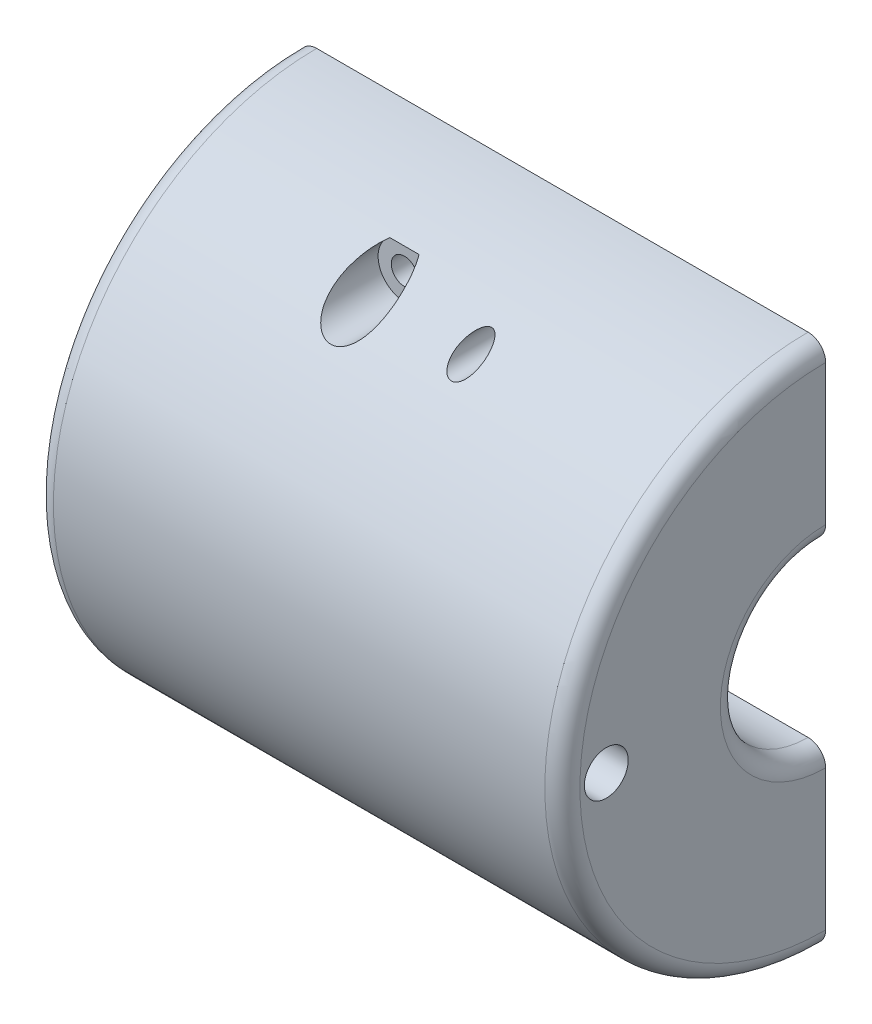
from build123d import *

# Parameters (mm, degrees)
SKETCH1_R               = 38.1
BOSS_EXTRUDE1_DEPTH     = 25.4
SKETCH2_R               = 38.1
SKETCH2_R_2             = 25.4
BOSS_EXTRUDE2_DEPTH     = 25.4
SKETCH3_R               = 38.1
BOSS_EXTRUDE3_DEPTH     = 25.4
SKETCH4_R               = 12.7
CUT_EXTRUDE1_DEPTH      = 77.2
FILLET1_R               = 2.54
SKETCH6_R               = 1.905
CUT_EXTRUDE2_DEPTH      = 39.1000001
CUT_EXTRUDE2_DEPTH_BACK = 39.1000001
SKETCH7_R               = 3.81
CUT_EXTRUDE3_DEPTH      = 25.4
SKETCH8_R               = 3.81
CUT_EXTRUDE4_DEPTH      = 25.4
CUT_EXTRUDE5_REACH      = 78.2
SKETCH9_W               = 50.8
SKETCH9_H               = 76.2
FILLET2_R               = 2.54
SKETCH10_R              = 3.175
CUT_EXTRUDE6_DEPTH      = 77.2
FILLET3_R               = 2.54


with BuildPart() as part:
    # Sketch1 → Boss-Extrude1 (new body)
    with BuildSketch(Plane(origin=(0, 0, 0), x_dir=(0, 0, -1), z_dir=(1, 0, 0))):
        Circle(SKETCH1_R)
    extrude(amount=BOSS_EXTRUDE1_DEPTH)

    # Sketch2 → Boss-Extrude2 (add)
    with BuildSketch(Plane(origin=(25.4, 0, 0), x_dir=(0, 0, -1), z_dir=(1, 0, 0))):
        Circle(SKETCH2_R)
        Circle(SKETCH2_R_2, mode=Mode.SUBTRACT)
    extrude(amount=BOSS_EXTRUDE2_DEPTH)

    # Sketch3 → Boss-Extrude3 (add)
    with BuildSketch(Plane(origin=(50.8, 0, 0), x_dir=(0, 0, -1), z_dir=(1, 0, 0))):
        Circle(SKETCH3_R)
    extrude(amount=BOSS_EXTRUDE3_DEPTH)

    # Sketch4 → Cut-Extrude1 (cut, through all)
    with BuildSketch(Plane(origin=(76.2, 0, 0), x_dir=(0, 0, -1), z_dir=(1, 0, 0))):
        Circle(SKETCH4_R)
    extrude(amount=-CUT_EXTRUDE1_DEPTH, mode=Mode.SUBTRACT)

    # Fillet1
    fillet1_edges = [part.edges().sort_by_distance(p)[0] for p in [
        (76.2, 0, 38.1),
        (0, 0, 38.1),
    ]]
    fillet(fillet1_edges, radius=FILLET1_R)

    # Sketch6 → Cut-Extrude2 (cut, two sides)
    with BuildSketch(Plane.XY) as cut_extrude2_sk:
        with Locations((30.48, 31.75)):
            Circle(SKETCH6_R)
        with Locations((45.72, 31.75)):
            Circle(SKETCH6_R)
        with Locations((30.48, -31.75)):
            Circle(SKETCH6_R)
        with Locations((45.72, -31.75)):
            Circle(SKETCH6_R)
    extrude(amount=CUT_EXTRUDE2_DEPTH, mode=Mode.SUBTRACT)
    extrude(cut_extrude2_sk.sketch, amount=-CUT_EXTRUDE2_DEPTH_BACK, mode=Mode.SUBTRACT)

    # Sketch7 → Cut-Extrude3 (cut)
    with BuildSketch(Plane.XY.offset(15.24)):
        with Locations((30.48, 31.75)):
            Circle(SKETCH7_R)
        with Locations((45.72, -31.75)):
            Circle(SKETCH7_R)
    extrude(amount=CUT_EXTRUDE3_DEPTH, mode=Mode.SUBTRACT)

    # Sketch8 → Cut-Extrude4 (cut)
    with BuildSketch(Plane.XY.offset(-15.24)):
        with Locations((45.72, 31.75)):
            Circle(SKETCH8_R)
        with Locations((30.48, -31.75)):
            Circle(SKETCH8_R)
    extrude(amount=-CUT_EXTRUDE4_DEPTH, mode=Mode.SUBTRACT)

    # Sketch9 → Cut-Extrude5 (cut, up to next)
    with BuildSketch(Plane.ZY, mode=Mode.PRIVATE) as cut_extrude5_sk1:
        with Locations((-25.4, 0)):
            Rectangle(SKETCH9_W, SKETCH9_H)
    cut_extrude5_tool1 = extrude(cut_extrude5_sk1.sketch, amount=-CUT_EXTRUDE5_REACH, mode=Mode.PRIVATE) & part.part
    add(cut_extrude5_tool1.solids().sort_by_distance((0, 0, -25.4))[0], mode=Mode.SUBTRACT)

    # Fillet2
    fillet2_edges = [part.edges().sort_by_distance(p)[0] for p in [
        (25.4, 0, 12.7),
        (50.8, 0, 12.7),
    ]]
    fillet(fillet2_edges, radius=FILLET2_R)

    # Sketch10 → Cut-Extrude6 (cut, through all)
    with BuildSketch(Plane(origin=(76.2, 0, 0), x_dir=(0, 0, -1), z_dir=(1, 0, 0))):
        with Locations((-31.75, 0)):
            Circle(SKETCH10_R)
    extrude(amount=-CUT_EXTRUDE6_DEPTH, mode=Mode.SUBTRACT)

    # Fillet3
    fillet3_edges = [part.edges().sort_by_distance(p)[0] for p in [
        (0, 0, 12.7),
        (76.2, 0, 12.7),
    ]]
    fillet(fillet3_edges, radius=FILLET3_R)


solid = part.part
